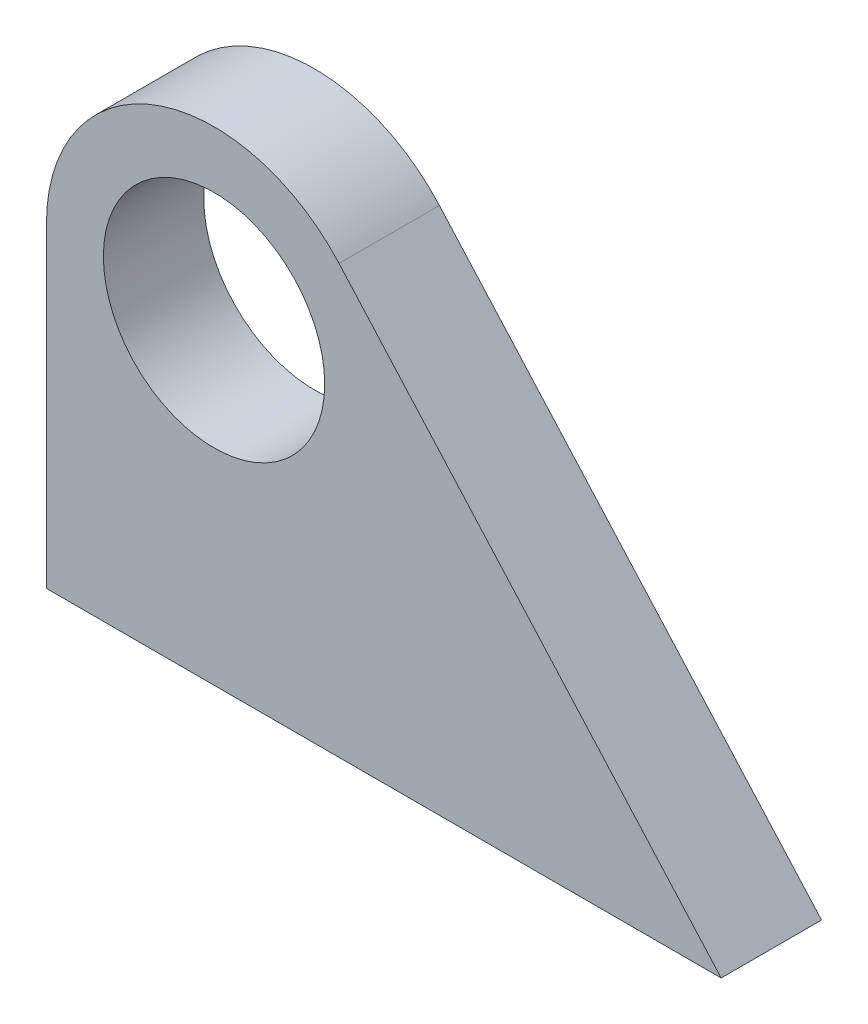
from build123d import *

# Parameters (mm, degrees)
CROQUIS1_R              = 3.5
SALIENTE_EXTRUIR1_DEPTH = 3.175


with BuildPart() as part:
    # Croquis1 → Saliente-Extruir1 (new body)
    with BuildSketch(Plane.XY):
        with BuildLine():
            Line((0, 0), (0, 10))
            ThreePointArc((0, 10), (3.4103651, 14.951694654), (9.25255847, 13.530903786))
            Line((9.25255847, 13.530903786), (21.34, 0))
            Line((21.34, 0), (0, 0))
        make_face()
        with Locations((5.3, 10)):
            Circle(CROQUIS1_R, mode=Mode.SUBTRACT)
    extrude(amount=SALIENTE_EXTRUIR1_DEPTH)


solid = part.part
